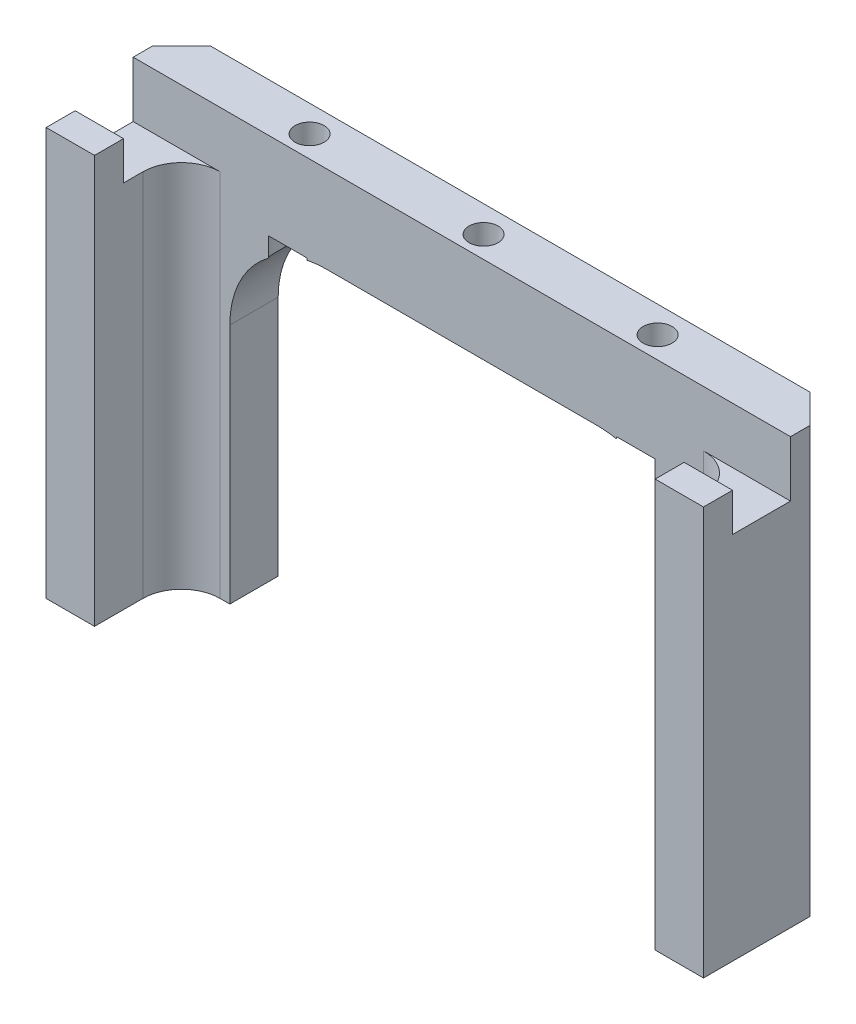
from build123d import *

# Parameters (mm, degrees)
BOSS_EXTRUDE1_DEPTH     = 44
SKETCH2_W               = 48
SKETCH2_H               = 35
CUT_EXTRUDE1_DEPTH      = 15
FILLET1_R               = 10
SKETCH3_R               = 1.5
CUT_EXTRUDE2_DEPTH      = 36
CUT_EXTRUDE2_DEPTH_BACK = 10
CHAMFER1_SIZE           = 3
SKETCH4_W               = 9
SKETCH4_H               = 1.8
CUT_EXTRUDE3_DEPTH      = 35
CUT_EXTRUDE3_DEPTH_BACK = 35
SKETCH5_W               = 6
SKETCH5_H               = 3.971430967
CUT_EXTRUDE4_DEPTH      = 35
CUT_EXTRUDE4_DEPTH_BACK = 35
SKETCH6_R               = 3
CUT_EXTRUDE6_DEPTH      = 11
FILLET2_R               = 4


with BuildPart() as part:
    # Sketch1 → Boss-Extrude1 (new body)
    with BuildSketch(Plane(origin=(0, 0, 0), x_dir=(1, 0, 0), z_dir=(0, 1, 0))):
        Polygon((34, 0), (-34, 0), (-34, -14), (-29, -14), (-29, -5), (29, -5), (29, -14), (34, -14), align=None)
    extrude(amount=-BOSS_EXTRUDE1_DEPTH)

    # Sketch2 → Cut-Extrude1 (cut, through all)
    with BuildSketch(Plane(origin=(0, 0, 0), x_dir=(-1, 0, 0), z_dir=(0, 0, -1))):
        with Locations((0, -26.5)):
            Rectangle(SKETCH2_W, SKETCH2_H)
    extrude(amount=-CUT_EXTRUDE1_DEPTH, mode=Mode.SUBTRACT)

    # Fillet1
    fillet1_edges = [part.edges().sort_by_distance(p)[0] for p in [
        (-24, -9, 2.5),
        (24, -9, 2.5),
    ]]
    fillet(fillet1_edges, radius=FILLET1_R)

    # Sketch3 → Cut-Extrude2 (cut, two sides)
    with BuildSketch(Plane.XZ.offset(9)) as cut_extrude2_sk:
        with Locations((0, 2.75)):
            Circle(SKETCH3_R)
        with Locations((-18, 2.75)):
            Circle(SKETCH3_R)
        with Locations((18, 2.75)):
            Circle(SKETCH3_R)
    extrude(amount=CUT_EXTRUDE2_DEPTH, mode=Mode.SUBTRACT)
    extrude(cut_extrude2_sk.sketch, amount=-CUT_EXTRUDE2_DEPTH_BACK, mode=Mode.SUBTRACT)

    # Chamfer1
    chamfer1_edges = [part.edges().sort_by_distance(p)[0] for p in [
        (-34, -22, 0),
        (34, -22, 0),
    ]]
    chamfer(chamfer1_edges, length=CHAMFER1_SIZE)

    # Sketch4 → Cut-Extrude3 (cut, two sides)
    with BuildSketch(Plane(origin=(0, 0, 0), x_dir=(0, 0, -1), z_dir=(1, 0, 0))) as cut_extrude3_sk:
        with Locations((-9.5, -0.9)):
            Rectangle(SKETCH4_W, SKETCH4_H)
    extrude(amount=CUT_EXTRUDE3_DEPTH, mode=Mode.SUBTRACT)
    extrude(cut_extrude3_sk.sketch, amount=-CUT_EXTRUDE3_DEPTH_BACK, mode=Mode.SUBTRACT)

    # Sketch5 → Cut-Extrude4 (cut, two sides)
    with BuildSketch(Plane(origin=(0, 0, 0), x_dir=(0, 0, -1), z_dir=(1, 0, 0))) as cut_extrude4_sk:
        with Locations((-8, -3.785715484)):
            Rectangle(SKETCH5_W, SKETCH5_H)
    extrude(amount=CUT_EXTRUDE4_DEPTH, mode=Mode.SUBTRACT)
    extrude(cut_extrude4_sk.sketch, amount=-CUT_EXTRUDE4_DEPTH_BACK, mode=Mode.SUBTRACT)

    # Sketch6 → Cut-Extrude6 (cut)
    with BuildSketch(Plane.XZ.offset(9)):
        with Locations((0, 2.75)):
            Circle(SKETCH6_R)
        with Locations((18, 2.75)):
            Circle(SKETCH6_R)
        with Locations((-18, 2.75)):
            Circle(SKETCH6_R)
    extrude(amount=CUT_EXTRUDE6_DEPTH, mode=Mode.SUBTRACT)

    # Fillet2
    fillet2_edges = [part.edges().sort_by_distance(p)[0] for p in [
        (29, -24.885715483, 5),
        (-29, -24.885715483, 5),
    ]]
    fillet(fillet2_edges, radius=FILLET2_R)


solid = part.part
